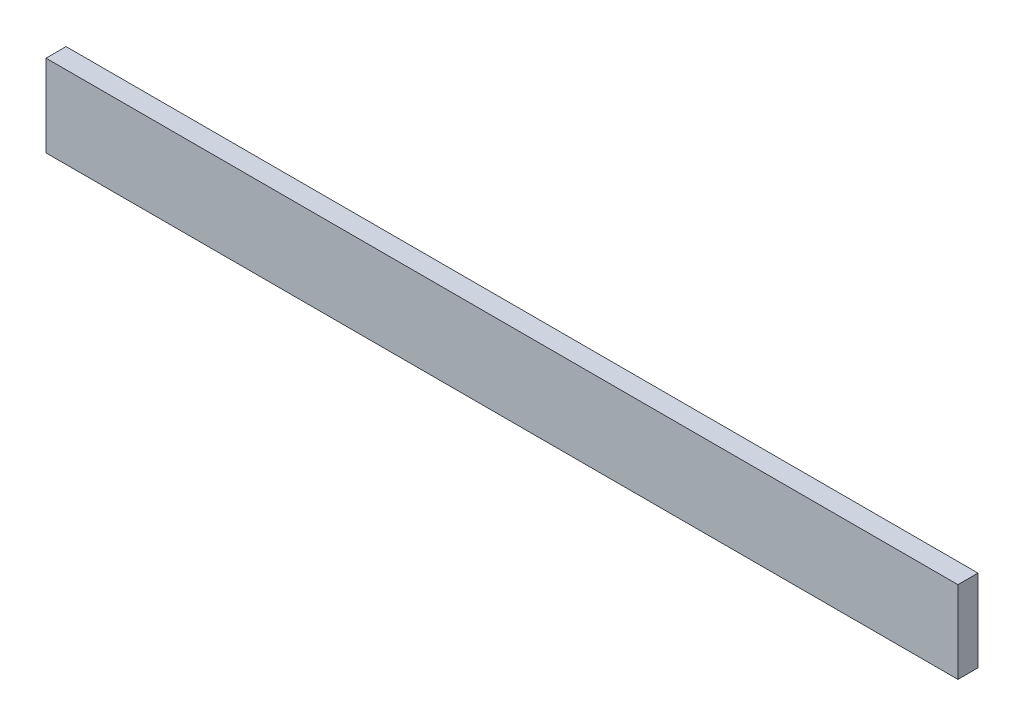
from build123d import *

# Parameters (mm, degrees)
ESQUISSE1_W      = 1000
ESQUISSE1_H      = 90
EXTRUSION1_DEPTH = 22


with BuildPart() as part:
    # Esquisse1 → Extrusion1 (new body)
    with BuildSketch(Plane.XY):
        with Locations((500, 45)):
            Rectangle(ESQUISSE1_W, ESQUISSE1_H)
    extrude(amount=EXTRUSION1_DEPTH)


solid = part.part
